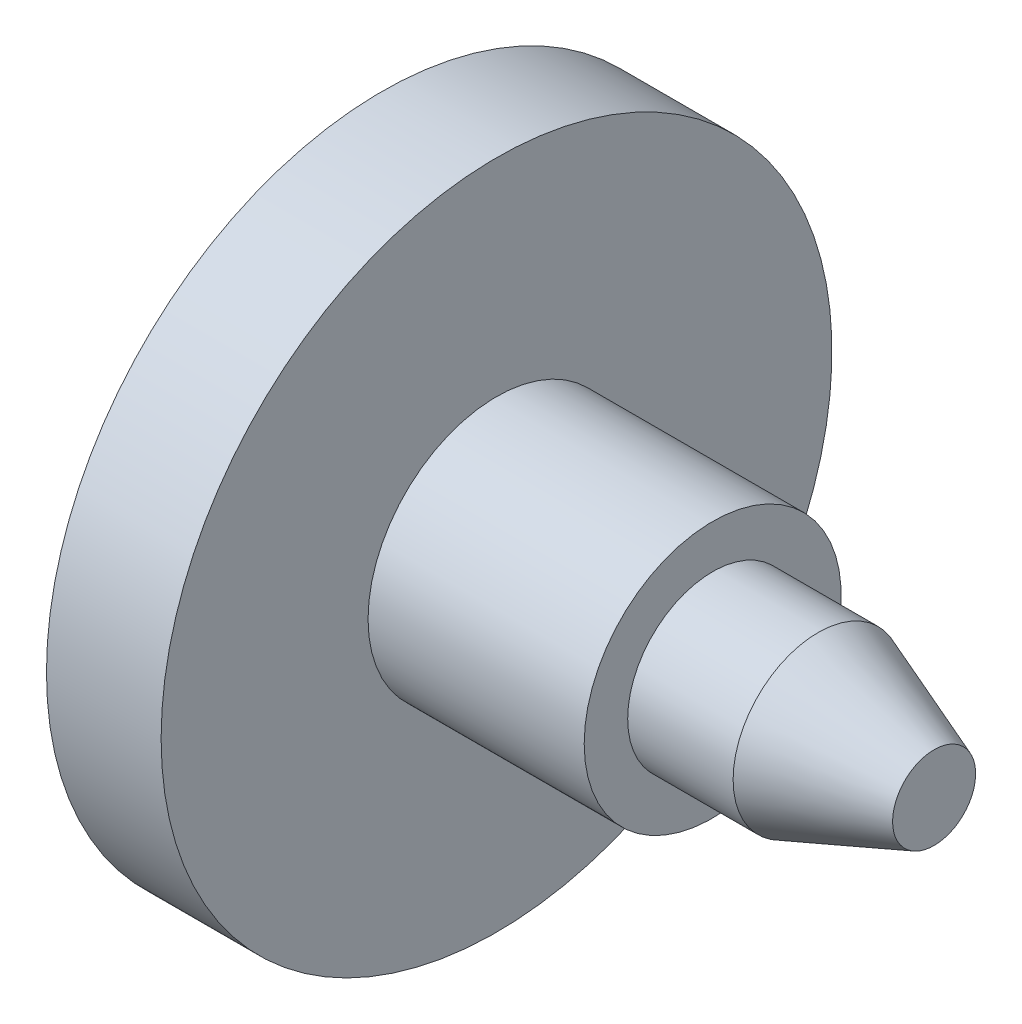
from build123d import *


with BuildPart() as part:
    # Sketch2 → Revolve1 (revolve)
    with BuildSketch(Plane.XY):
        Polygon((-23.190799417, 67.844377136), (-23.190799417, 35.588307849), (-45.851602622, 35.588307849), (-45.851602622, 25.991460789), (-29.858438501, 25.991460789), (-29.858438501, 11.329611113), (60.390415797, 11.329611113), (78.640830079, 5.464871243), (78.640830079, 0), (88.504256224, 0), (88.504256224, 8.397241178), (65.045296743, 17.194350983), (43.718969942, 17.194350983), (43.718969942, 25.991460789), (0, 25.991460789), (0, 67.844377136), align=None)
    revolve(axis=Axis((-97.165567149, 0, 0), (1, 0, 0)))


solid = part.part
